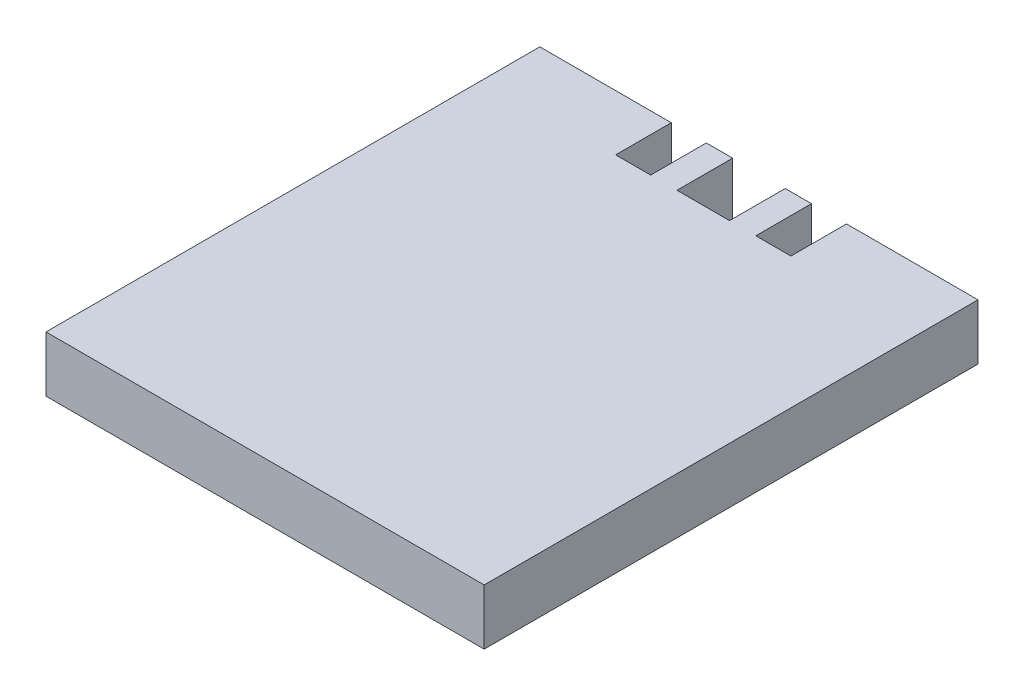
from build123d import *

# Parameters (mm, degrees)
BOSS_EXTRUDE1_DEPTH = 3.175


with BuildPart() as part:
    # Sketch1 → Boss-Extrude1 (new body)
    with BuildSketch(Plane(origin=(0, 0, 0), x_dir=(1, 0, 0), z_dir=(0, 1, 0))):
        Polygon((0, 0), (25, 0), (25, 25), (25, 28.175), (17.5, 28.175), (17.5, 25), (15.5, 25), (15.5, 28.175), (14, 28.175), (14, 25), (12.5, 25), (11, 25), (11, 28.175), (9.5, 28.175), (9.5, 25), (7.5, 25), (7.5, 28.175), (0, 28.175), (0, 25), align=None)
    extrude(amount=BOSS_EXTRUDE1_DEPTH)


solid = part.part
